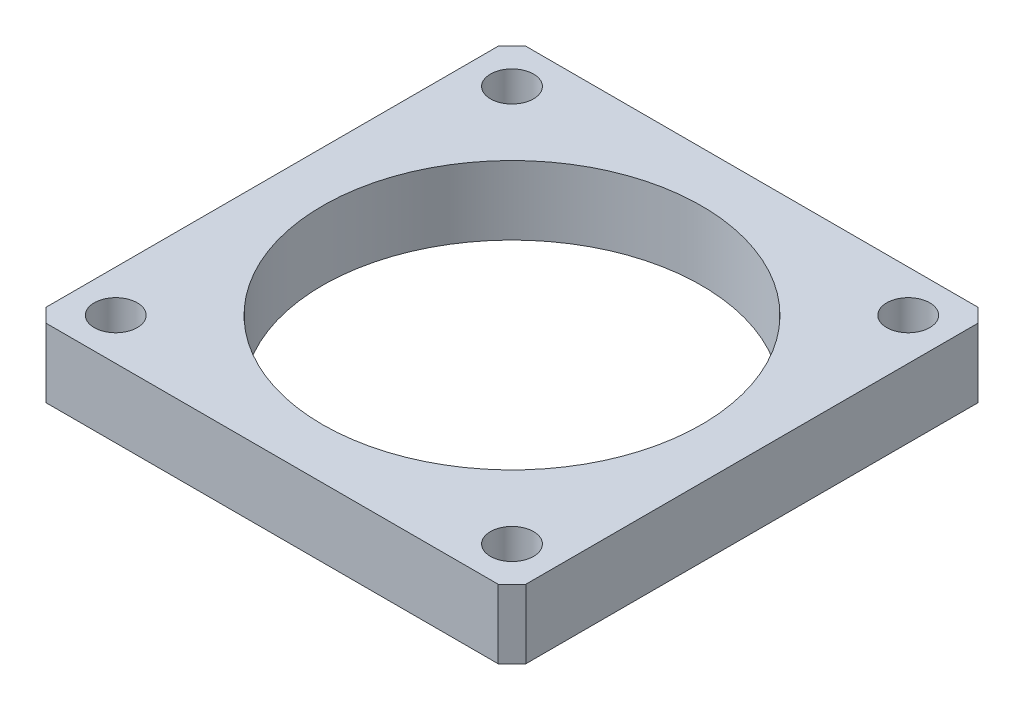
from build123d import *

# Parameters (mm, degrees)
SKETCH_2_W      = 27.85
SKETCH_2_H      = 27.85
SKETCH_2_R      = 1.25
SKETCH_2_R_2    = 11
EXTRUDE_1_DEPTH = 4
CHAMFER_1_SIZE  = 0.8


with BuildPart() as part:
    # Эскиз2 → Бобышка-Вытянуть1 (new body)
    with BuildSketch(Plane(origin=(0, 0, 0), x_dir=(1, 0, 0), z_dir=(0, 1, 0))):
        Rectangle(SKETCH_2_W, SKETCH_2_H)
        with Locations((-11.5, 11.5)):
            Circle(SKETCH_2_R, mode=Mode.SUBTRACT)
        with Locations((-11.5, -11.5)):
            Circle(SKETCH_2_R, mode=Mode.SUBTRACT)
        with Locations((11.5, -11.5)):
            Circle(SKETCH_2_R, mode=Mode.SUBTRACT)
        with Locations((11.5, 11.5)):
            Circle(SKETCH_2_R, mode=Mode.SUBTRACT)
        Circle(SKETCH_2_R_2, mode=Mode.SUBTRACT)
    extrude(amount=EXTRUDE_1_DEPTH)

    # Фаска1
    chamfer_1_edges = [part.edges().sort_by_distance(p)[0] for p in [
        (13.925, 2, -13.925),
        (13.925, 2, 13.925),
        (-13.925, 2, 13.925),
        (-13.925, 2, -13.925),
    ]]
    chamfer(chamfer_1_edges, length=CHAMFER_1_SIZE)


solid = part.part
